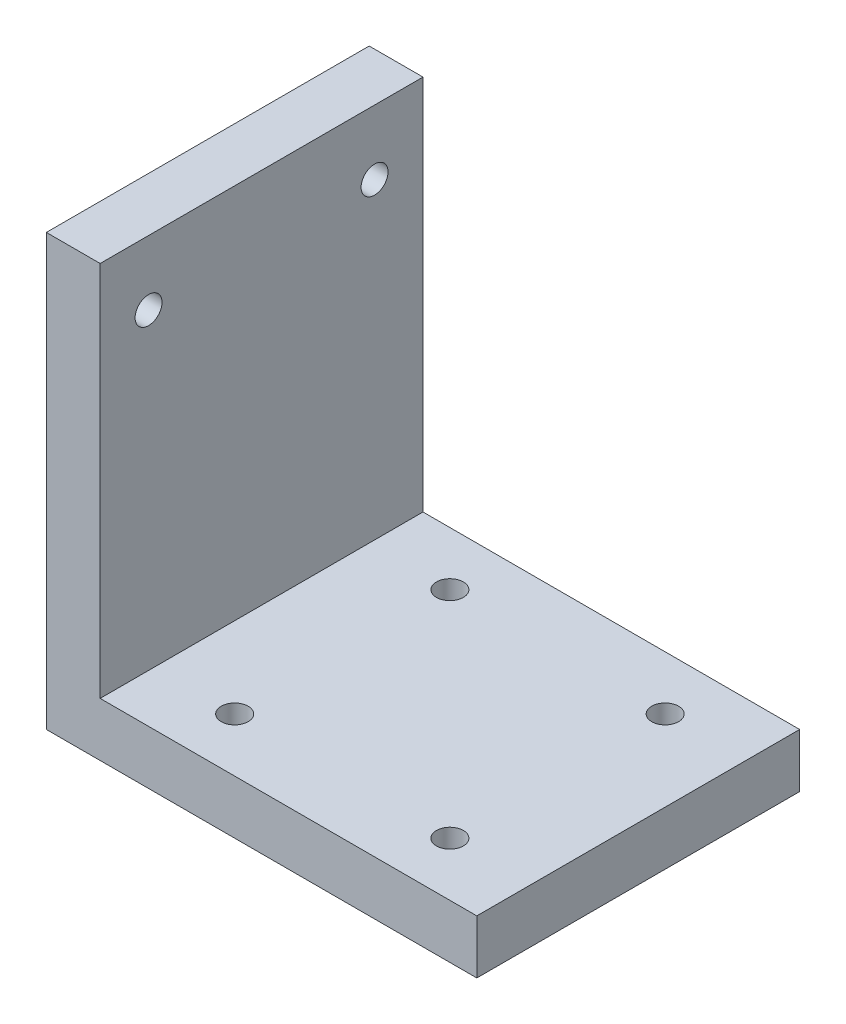
from build123d import *

# Parameters (mm, degrees)
EXTRUDE_1_DEPTH        = 60
HOLE_WIZARD_M6_1_D     = 5
HOLE_WIZARD_M6_1_DEPTH = 15
HOLE_WIZARD_M6_1_TIP   = 1.502151548
HOLE_WIZARD_M6_2_D     = 5
HOLE_WIZARD_M6_2_DEPTH = 15
HOLE_WIZARD_M6_2_TIP   = 1.502151548


with BuildPart() as part:
    # 草图1 → 凸台-拉伸1 (new body)
    with BuildSketch(Plane.XY):
        Polygon((0, 80), (0, 0), (80, 0), (80, 10), (10, 10), (10, 80), align=None)
    extrude(amount=EXTRUDE_1_DEPTH)

    # M6 螺纹孔1
    with Locations(Plane(origin=(65, 0, 50), x_dir=(0, 0, -1), z_dir=(0, -1, 0))):
        with Locations((0, 0), (40, 0), (40, -40), (0, -40)):
            Hole(HOLE_WIZARD_M6_1_D / 2, depth=HOLE_WIZARD_M6_1_DEPTH)
            with Locations((0, 0, -(HOLE_WIZARD_M6_1_DEPTH + HOLE_WIZARD_M6_1_TIP / 2))):  # 118° drill point
                Cone(0, HOLE_WIZARD_M6_1_D / 2, HOLE_WIZARD_M6_1_TIP, mode=Mode.SUBTRACT)

    # M6 螺纹孔2
    with Locations(Plane(origin=(0, 68, 9), x_dir=(0, 0, -1), z_dir=(-1, 0, 0))):
        with Locations((0, 0), (-42, 0)):
            Hole(HOLE_WIZARD_M6_2_D / 2, depth=HOLE_WIZARD_M6_2_DEPTH)
            with Locations((0, 0, -(HOLE_WIZARD_M6_2_DEPTH + HOLE_WIZARD_M6_2_TIP / 2))):  # 118° drill point
                Cone(0, HOLE_WIZARD_M6_2_D / 2, HOLE_WIZARD_M6_2_TIP, mode=Mode.SUBTRACT)


solid = part.part
